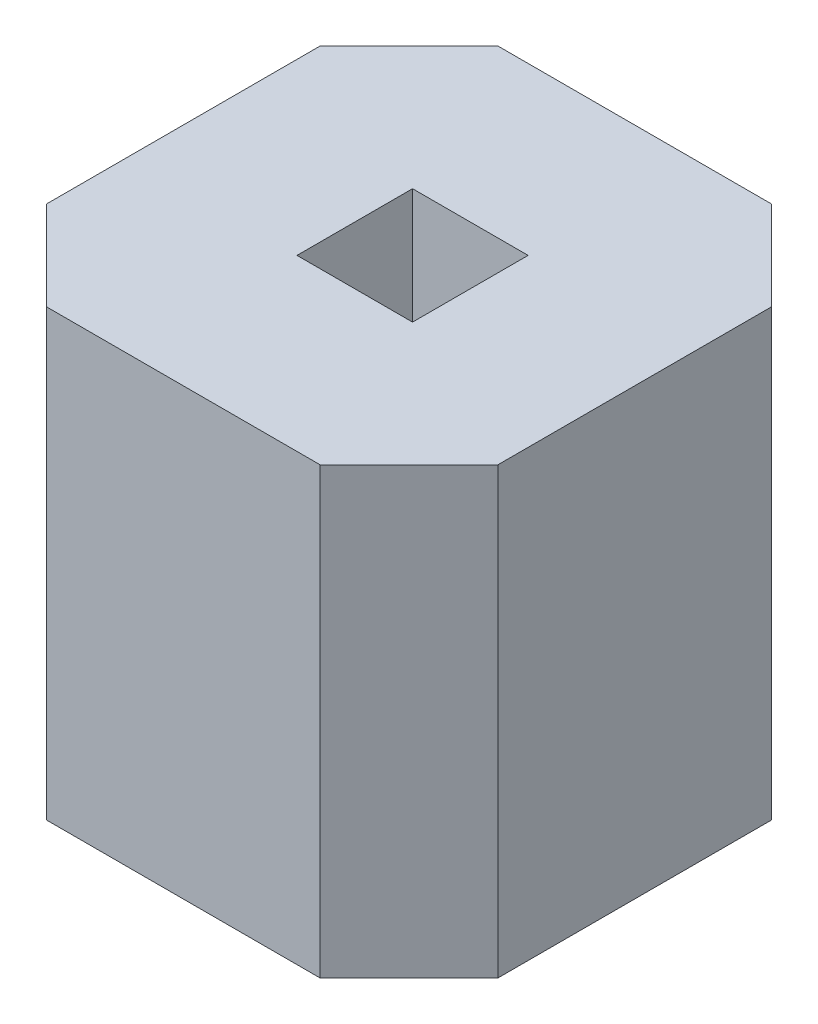
from build123d import *

# Parameters (mm, degrees)
SKETCH1_W           = 0.65
SKETCH1_H           = 0.65
BOSS_EXTRUDE1_DEPTH = 2.5


with BuildPart() as part:
    # Sketch1 → Boss-Extrude1 (new body)
    with BuildSketch(Plane(origin=(0, 0, 0), x_dir=(1, 0, 0), z_dir=(0, 1, 0))):
        Polygon((0, 2.04), (0.5, 2.54), (2.04, 2.54), (2.54, 2.04), (2.54, 0.5), (2.04, 0), (0.5, 0), (0, 0.5), align=None)
        with Locations((1.28, 1.28)):
            Rectangle(SKETCH1_W, SKETCH1_H, mode=Mode.SUBTRACT)
    extrude(amount=BOSS_EXTRUDE1_DEPTH)


solid = part.part
